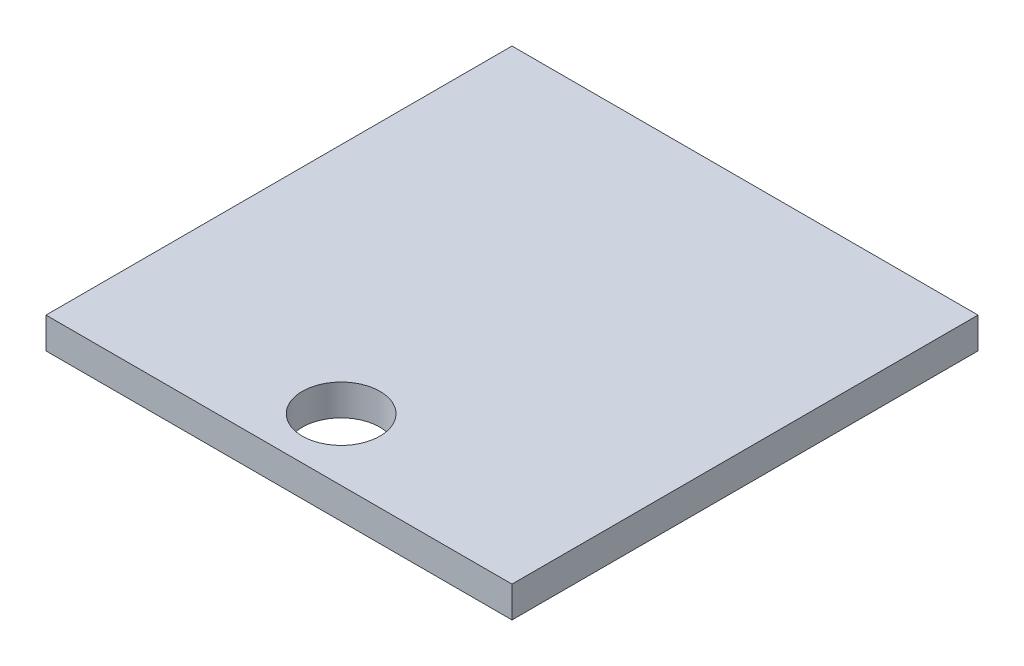
from build123d import *

# Parameters (mm, degrees)
SKETCH_1_W      = 15
SKETCH_1_H      = 15
SKETCH_1_R      = 1.25
EXTRUDE_1_DEPTH = 1


with BuildPart() as part:
    # 草图1 → 凸台-拉伸1 (new body)
    with BuildSketch(Plane(origin=(0, 0, 0), x_dir=(1, 0, 0), z_dir=(0, 1, 0))):
        Rectangle(SKETCH_1_W, SKETCH_1_H)
        with Locations((0, -5.5)):
            Circle(SKETCH_1_R, mode=Mode.SUBTRACT)
    extrude(amount=EXTRUDE_1_DEPTH)


solid = part.part
